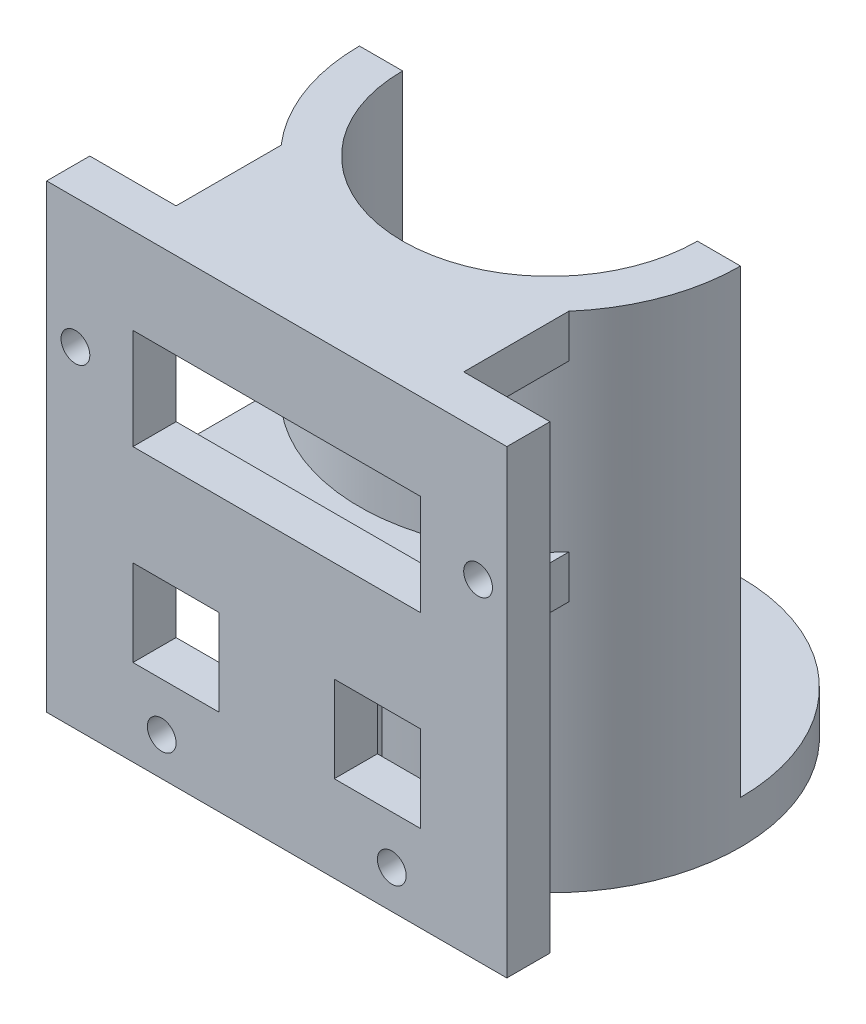
from build123d import *

# Parameters (mm, degrees)
SKETCH1_W                = 32
SKETCH1_H                = 32
SKETCH1_R                = 1
SKETCH1_W_2              = 20
SKETCH1_H_2              = 7
SKETCH1_W_3              = 6
SKETCH1_H_3              = 6
BOSS_EXTRUDE1_DEPTH      = 3
SKETCH2_R                = 13.25
SKETCH2_R_2              = 1
BOSS_EXTRUDE2_DEPTH      = 3
BOSS_EXTRUDE3_DEPTH      = 32
BOSS_EXTRUDE4_REACH      = 40.374
BOSS_EXTRUDE4_END_RADIUS = 13.25
SKETCH4_W                = 20
SKETCH4_H                = 3
SKETCH6_R                = 1
CUT_EXTRUDE1_DEPTH       = 41.707032562


with BuildPart() as part:
    # Sketch1 → Boss-Extrude1 (new body)
    with BuildSketch(Plane.XY):
        Rectangle(SKETCH1_W, SKETCH1_H)
        with Locations((14, 7)):
            Circle(SKETCH1_R, mode=Mode.SUBTRACT)
        with Locations(Location((-14, 7, 0), (0, 0, 180))):
            Circle(SKETCH1_R, mode=Mode.SUBTRACT)
        with Locations((-8, -13.347936253)):
            Circle(SKETCH1_R, mode=Mode.SUBTRACT)
        with Locations(Location((8, -13.347936253, 0), (0, 0, 180))):
            Circle(SKETCH1_R, mode=Mode.SUBTRACT)
        with Locations((0, 6.5)):
            Rectangle(SKETCH1_W_2, SKETCH1_H_2, mode=Mode.SUBTRACT)
        with Locations((-7, -7)):
            Rectangle(SKETCH1_W_3, SKETCH1_H_3, mode=Mode.SUBTRACT)
        with Locations((7, -7)):
            Rectangle(SKETCH1_W_3, SKETCH1_H_3, mode=Mode.SUBTRACT)
    extrude(amount=BOSS_EXTRUDE1_DEPTH)



with BuildPart() as body_2:
    # Sketch2 → Boss-Extrude2 (new body)
    with BuildSketch(Plane.XZ.offset(16)):
        with Locations(Location((0, -16, 0), (0, 0, 270))):
            Circle(SKETCH2_R)
        with Locations(Location((-8, -16, 0), (0, 0, 270))):
            Circle(SKETCH2_R_2, mode=Mode.SUBTRACT)
        with Locations(Location((0, -8, 0), (0, 0, 270))):
            Circle(SKETCH2_R_2, mode=Mode.SUBTRACT)
        with Locations(Location((8, -16, 0), (0, 0, 270))):
            Circle(SKETCH2_R_2, mode=Mode.SUBTRACT)
        with Locations(Location((0, -24, 0), (0, 0, 270))):
            Circle(SKETCH2_R_2, mode=Mode.SUBTRACT)
    extrude(amount=BOSS_EXTRUDE2_DEPTH)

    # Sketch3 → Boss-Extrude3 (add)
    with BuildSketch(Plane(origin=(0, -16, 0), x_dir=(1, 0, 0), z_dir=(0, 1, 0))):
        with BuildLine():
            Line((-13.25, 16), (-10.25, 16))
            ThreePointArc((-10.25, 16), (0, 5.75), (10.25, 16))
            Line((10.25, 16), (13.25, 16))
            ThreePointArc((13.25, 16), (0, 2.75), (-13.25, 16))
        make_face()
    extrude(amount=BOSS_EXTRUDE3_DEPTH)


with BuildPart() as part_1:
    add(part.part)

    add(body_2.part)  # Boss-Extrude4 merges body 2
    # Boss-Extrude4: up to this cylinder (the profile starts outside it)
    boss_extrude4_end = Plane(origin=(0, 5.411232, -16), z_dir=(0, 1, 0)) * Cylinder(BOSS_EXTRUDE4_END_RADIUS, 126.425536, mode=Mode.PRIVATE)
    # Sketch4 → Boss-Extrude4 (add, up to the surface)
    with BuildSketch(Plane(origin=(0, 0, 0), x_dir=(-1, 0, 0), z_dir=(0, 0, -1)), mode=Mode.PRIVATE) as boss_extrude4_sk1:
        with Locations((0, 14.5)):
            Rectangle(SKETCH4_W, SKETCH4_H)
    boss_extrude4_tool1 = extrude(boss_extrude4_sk1.sketch, amount=BOSS_EXTRUDE4_REACH, mode=Mode.PRIVATE) - boss_extrude4_end
    add(boss_extrude4_tool1.solids().sort_by_distance((0, 14.5, 0))[0])
    # Sketch4 → Boss-Extrude4 (add, up to the surface)
    with BuildSketch(Plane(origin=(0, 0, 0), x_dir=(-1, 0, 0), z_dir=(0, 0, -1)), mode=Mode.PRIVATE) as boss_extrude4_sk2:
        Polygon((10, 1.5), (-10, 1.5), (-10, -1.5), (-1.5, -1.5), (-1.5, -16), (1.5, -16), (1.5, -1.5), (10, -1.5), align=None)
    boss_extrude4_tool2 = extrude(boss_extrude4_sk2.sketch, amount=BOSS_EXTRUDE4_REACH, mode=Mode.PRIVATE) - boss_extrude4_end
    add(boss_extrude4_tool2.solids().sort_by_distance((0, -3.677536, 0))[0])

    # Sketch6 → Cut-Extrude1 (cut, through all)
    with BuildSketch(Plane.XY.offset(3)):
        with Locations(Location((8, -13.347936253, 0), (0, 0, 180))):
            Circle(SKETCH6_R)
        with Locations((-8, -13.347936253)):
            Circle(SKETCH6_R)
    extrude(amount=-CUT_EXTRUDE1_DEPTH, mode=Mode.SUBTRACT)


solid = part_1.part
